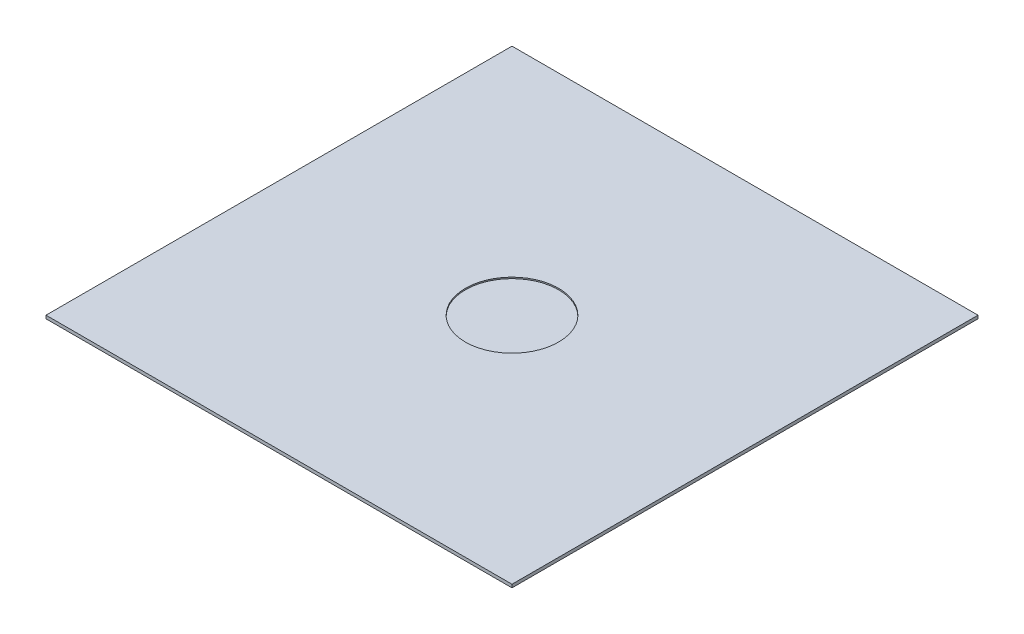
from build123d import *

# Parameters (mm, degrees)
SKETCH1_W           = 25
SKETCH1_H           = 25
BOSS_EXTRUDE1_DEPTH = 0.17
SKETCH2_R           = 2.5
CUT_EXTRUDE1_DEPTH  = 0.07


with BuildPart() as part:
    # Sketch1 → Boss-Extrude1 (new body)
    with BuildSketch(Plane(origin=(0, 0, 0), x_dir=(1, 0, 0), z_dir=(0, 1, 0))):
        Rectangle(SKETCH1_W, SKETCH1_H)
    extrude(amount=BOSS_EXTRUDE1_DEPTH)

    # Sketch2 → Cut-Extrude1 (cut)
    with BuildSketch(Plane(origin=(0, 0.17, 0), x_dir=(1, 0, 0), z_dir=(0, 1, 0))):
        Circle(SKETCH2_R)
    extrude(amount=-CUT_EXTRUDE1_DEPTH, mode=Mode.SUBTRACT)


solid = part.part
